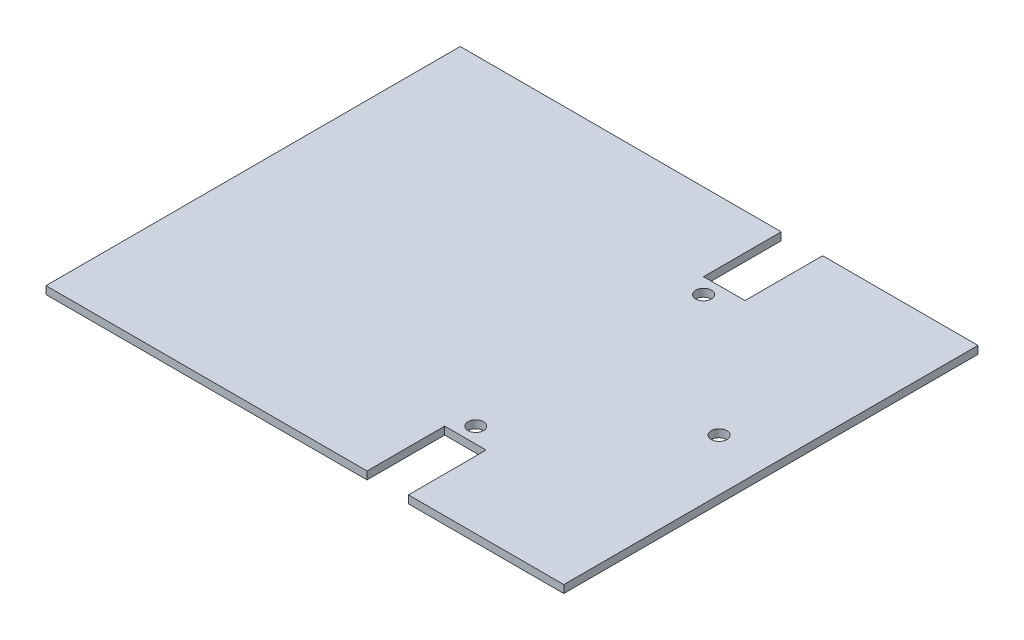
from build123d import *

# Parameters (mm, degrees)
SKETCH1_W           = 100
SKETCH1_H           = 80
BOSS_EXTRUDE1_DEPTH = 1.5
CUT_EXTRUDE1_REACH  = 3.5
SKETCH2_W           = 8
SKETCH2_H           = 15
CUT_EXTRUDE2_REACH  = 3.5
SKETCH3_R           = 1.5


with BuildPart() as part:
    # Sketch1 → Boss-Extrude1 (new body)
    with BuildSketch(Plane(origin=(0, 0, 0), x_dir=(1, 0, 0), z_dir=(0, 1, 0))):
        with Locations((50, 40)):
            Rectangle(SKETCH1_W, SKETCH1_H)
    extrude(amount=BOSS_EXTRUDE1_DEPTH)

    # Sketch2 → Cut-Extrude1 (cut, up to next)
    with BuildSketch(Plane(origin=(0, 1.5, 0), x_dir=(1, 0, 0), z_dir=(0, 1, 0)), mode=Mode.PRIVATE) as cut_extrude1_sk1:
        with Locations((66, 72.5)):
            Rectangle(SKETCH2_W, SKETCH2_H)
    cut_extrude1_tool1 = extrude(cut_extrude1_sk1.sketch, amount=-CUT_EXTRUDE1_REACH, mode=Mode.PRIVATE) & part.part
    add(cut_extrude1_tool1.solids().sort_by_distance((66, 1.5, -72.5))[0], mode=Mode.SUBTRACT)
    # Sketch2 → Cut-Extrude1 (cut, up to next)
    with BuildSketch(Plane(origin=(0, 1.5, 0), x_dir=(1, 0, 0), z_dir=(0, 1, 0)), mode=Mode.PRIVATE) as cut_extrude1_sk2:
        with Locations((66, 7.5)):
            Rectangle(SKETCH2_W, SKETCH2_H)
    cut_extrude1_tool2 = extrude(cut_extrude1_sk2.sketch, amount=-CUT_EXTRUDE1_REACH, mode=Mode.PRIVATE) & part.part
    add(cut_extrude1_tool2.solids().sort_by_distance((66, 1.5, -7.5))[0], mode=Mode.SUBTRACT)

    # Sketch3 → Cut-Extrude2 (cut, up to next)
    with BuildSketch(Plane(origin=(0, 1.5, 0), x_dir=(1, 0, 0), z_dir=(0, 1, 0)), mode=Mode.PRIVATE) as cut_extrude2_sk1:
        with Locations((65, 62)):
            Circle(SKETCH3_R)
    cut_extrude2_tool1 = extrude(cut_extrude2_sk1.sketch, amount=-CUT_EXTRUDE2_REACH, mode=Mode.PRIVATE) & part.part
    add(cut_extrude2_tool1.solids().sort_by_distance((65, 1.5, -62))[0], mode=Mode.SUBTRACT)
    # Sketch3 → Cut-Extrude2 (cut, up to next)
    with BuildSketch(Plane(origin=(0, 1.5, 0), x_dir=(1, 0, 0), z_dir=(0, 1, 0)), mode=Mode.PRIVATE) as cut_extrude2_sk2:
        with Locations((90, 40)):
            Circle(SKETCH3_R)
    cut_extrude2_tool2 = extrude(cut_extrude2_sk2.sketch, amount=-CUT_EXTRUDE2_REACH, mode=Mode.PRIVATE) & part.part
    add(cut_extrude2_tool2.solids().sort_by_distance((90, 1.5, -40))[0], mode=Mode.SUBTRACT)
    # Sketch3 → Cut-Extrude2 (cut, up to next)
    with BuildSketch(Plane(origin=(0, 1.5, 0), x_dir=(1, 0, 0), z_dir=(0, 1, 0)), mode=Mode.PRIVATE) as cut_extrude2_sk3:
        with Locations((65, 18)):
            Circle(SKETCH3_R)
    cut_extrude2_tool3 = extrude(cut_extrude2_sk3.sketch, amount=-CUT_EXTRUDE2_REACH, mode=Mode.PRIVATE) & part.part
    add(cut_extrude2_tool3.solids().sort_by_distance((65, 1.5, -18))[0], mode=Mode.SUBTRACT)


solid = part.part
